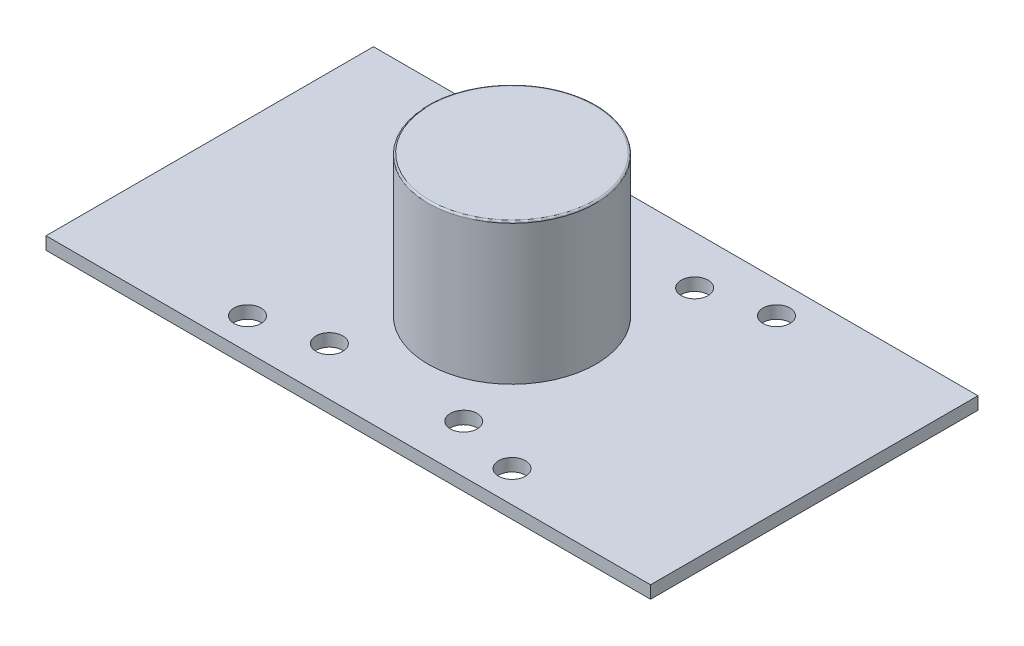
from build123d import *

# Parameters (mm, degrees)
SKETCH1_W           = 72
SKETCH1_H           = 39
BOSS_EXTRUDE1_DEPTH = 1.5
SKETCH2_R           = 10
BOSS_EXTRUDE2_DEPTH = 16.8
SKETCH3_R           = 1.6
CUT_EXTRUDE1_DEPTH  = 16.8
SKETCH4_R           = 1.6
CUT_EXTRUDE2_DEPTH  = 16.8
FILLET1_R           = 0.2


with BuildPart() as part:
    # Sketch1 → Boss-Extrude1 (new body)
    with BuildSketch(Plane(origin=(0, 0, 0), x_dir=(1, 0, 0), z_dir=(0, 1, 0))):
        with Locations((36, 19.5)):
            Rectangle(SKETCH1_W, SKETCH1_H)
    extrude(amount=BOSS_EXTRUDE1_DEPTH)

    # Sketch2 → Boss-Extrude2 (add)
    with BuildSketch(Plane(origin=(0, 1.5, 0), x_dir=(1, 0, 0), z_dir=(0, 1, 0))):
        with Locations((36, 19.5)):
            Circle(SKETCH2_R)
    extrude(amount=BOSS_EXTRUDE2_DEPTH)

    # Sketch3 → Cut-Extrude1 (cut)
    with BuildSketch(Plane(origin=(0, 1.5, 0), x_dir=(1, 0, 0), z_dir=(0, 1, 0))):
        with Locations((44, 5.75)):
            Circle(SKETCH3_R)
        with Locations((28, 5.75)):
            Circle(SKETCH3_R)
        with Locations((28, 33.25)):
            Circle(SKETCH3_R)
        with Locations((44, 33.25)):
            Circle(SKETCH3_R)
    extrude(amount=-CUT_EXTRUDE1_DEPTH, mode=Mode.SUBTRACT)

    # Sketch4 → Cut-Extrude2 (cut)
    with BuildSketch(Plane(origin=(0, 1.5, 0), x_dir=(1, 0, 0), z_dir=(0, 1, 0))):
        with Locations((51.75, 3.75)):
            Circle(SKETCH4_R)
        with Locations((51.75, 35.25)):
            Circle(SKETCH4_R)
        with Locations((20.25, 3.75)):
            Circle(SKETCH4_R)
        with Locations((20.25, 35.25)):
            Circle(SKETCH4_R)
    extrude(amount=-CUT_EXTRUDE2_DEPTH, mode=Mode.SUBTRACT)

    # Fillet1
    fillet1_edges = [part.edges().sort_by_distance(p)[0] for p in [
        (26, 18.3, -19.5),
    ]]
    fillet(fillet1_edges, radius=FILLET1_R)


solid = part.part
